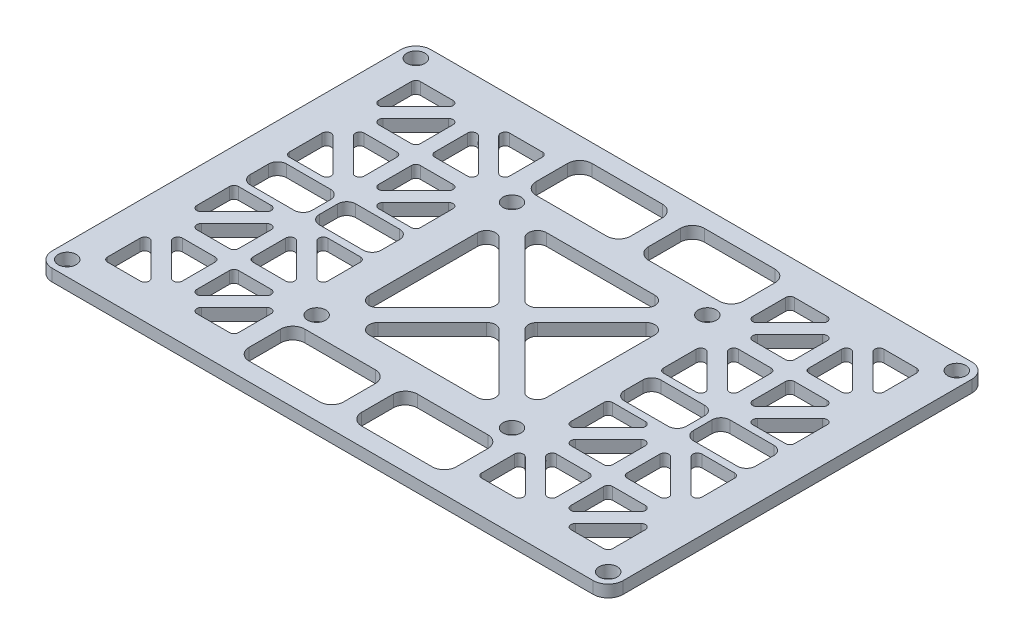
from build123d import *

# Parameters (mm, degrees)
SKETCH1_R           = 1.5
BOSS_EXTRUDE1_DEPTH = 2
SKETCH2_R           = 1.5
CUT_EXTRUDE1_DEPTH  = 3


with BuildPart() as part:
    # Sketch1 → Boss-Extrude1 (new body)
    with BuildSketch(Plane(origin=(0, 0, 0), x_dir=(1, 0, 0), z_dir=(0, 1, 0))):
        with BuildLine():
            Line((-45, -31.5), (45, -31.5))
            ThreePointArc((45, -31.5), (46.767766953, -30.767766953), (47.5, -29))
            Line((47.5, -29), (47.5, 29))
            ThreePointArc((47.5, 29), (46.767766953, 30.767766953), (45, 31.5))
            Line((45, 31.5), (-45, 31.5))
            ThreePointArc((-45, 31.5), (-46.767766953, 30.767766953), (-47.5, 29))
            Line((-47.5, 29), (-47.5, -29))
            ThreePointArc((-47.5, -29), (-46.767766953, -30.767766953), (-45, -31.5))
        make_face()
        with Locations((45, 29)):
            Circle(SKETCH1_R, mode=Mode.SUBTRACT)
        with Locations((45, -29)):
            Circle(SKETCH1_R, mode=Mode.SUBTRACT)
        with Locations((-45, 29)):
            Circle(SKETCH1_R, mode=Mode.SUBTRACT)
        with Locations((-45, -29)):
            Circle(SKETCH1_R, mode=Mode.SUBTRACT)
    extrude(amount=BOSS_EXTRUDE1_DEPTH)

    # Sketch2 → Cut-Extrude1 (cut, through all)
    with BuildSketch(Plane(origin=(0, 2, 0), x_dir=(1, 0, 0), z_dir=(0, 1, 0))):
        with Locations((-16.25, 16.25)):
            Circle(SKETCH2_R)
        with Locations((-16.25, -16.25)):
            Circle(SKETCH2_R)
        with Locations((16.25, 16.25)):
            Circle(SKETCH2_R)
        with Locations((16.25, -16.25)):
            Circle(SKETCH2_R)
        with BuildLine():
            Line((-12.189339828, 10.068019485), (-3.181980515, 1.060660172))
            ThreePointArc((-3.181980515, 1.060660172), (-2.742640687, 0), (-3.181980515, -1.060660172))
            Line((-3.181980515, -1.060660172), (-12.189339828, -10.068019485))
            ThreePointArc((-12.189339828, -10.068019485), (-13.824025149, -10.393178612), (-14.75, -9.007359313))
            Line((-14.75, -9.007359313), (-14.75, 9.007359313))
            ThreePointArc((-14.75, 9.007359313), (-13.824025149, 10.393178612), (-12.189339828, 10.068019485))
        make_face()
        with BuildLine():
            Line((1.060660172, 3.181980515), (10.068019485, 12.189339828))
            ThreePointArc((10.068019485, 12.189339828), (10.393178612, 13.824025149), (9.007359313, 14.75))
            Line((9.007359313, 14.75), (-9.007359313, 14.75))
            ThreePointArc((-9.007359313, 14.75), (-10.393178612, 13.824025149), (-10.068019485, 12.189339828))
            Line((-10.068019485, 12.189339828), (-1.060660172, 3.181980515))
            ThreePointArc((-1.060660172, 3.181980515), (0, 2.742640687), (1.060660172, 3.181980515))
        make_face()
        with BuildLine():
            Line((3.181980515, 1.060660172), (12.189339828, 10.068019485))
            ThreePointArc((12.189339828, 10.068019485), (13.824025149, 10.393178612), (14.75, 9.007359313))
            Line((14.75, 9.007359313), (14.75, -9.007359313))
            ThreePointArc((14.75, -9.007359313), (13.824025149, -10.393178612), (12.189339828, -10.068019485))
            Line((12.189339828, -10.068019485), (3.181980515, -1.060660172))
            ThreePointArc((3.181980515, -1.060660172), (2.742640687, 0), (3.181980515, 1.060660172))
        make_face()
        with BuildLine():
            Line((-9.007359313, -14.75), (9.007359313, -14.75))
            ThreePointArc((9.007359313, -14.75), (10.393178612, -13.824025149), (10.068019485, -12.189339828))
            Line((10.068019485, -12.189339828), (1.060660172, -3.181980515))
            ThreePointArc((1.060660172, -3.181980515), (0, -2.742640687), (-1.060660172, -3.181980515))
            Line((-1.060660172, -3.181980515), (-10.068019485, -12.189339828))
            ThreePointArc((-10.068019485, -12.189339828), (-10.393178612, -13.824025149), (-9.007359313, -14.75))
        make_face()
        with BuildLine():
            Line((35.832716447, 26.022056275), (41.272056275, 26.022056275))
            ThreePointArc((41.272056275, 26.022056275), (41.802386361, 25.802386361), (42.022056275, 25.272056275))
            Line((42.022056275, 25.272056275), (42.022056275, 19.832716447))
            ThreePointArc((42.022056275, 19.832716447), (41.559068849, 19.139806797), (40.741726189, 19.302386361))
            Line((40.741726189, 19.302386361), (35.302386361, 24.741726189))
            ThreePointArc((35.302386361, 24.741726189), (35.139806797, 25.559068849), (35.832716447, 26.022056275))
        make_face()
        with BuildLine():
            Line((33.605330086, 23.044669914), (39.044669914, 17.605330086))
            ThreePointArc((39.044669914, 17.605330086), (39.207249478, 16.787987426), (38.514339828, 16.325))
            Line((38.514339828, 16.325), (33.075, 16.325))
            ThreePointArc((33.075, 16.325), (32.544669914, 16.544669914), (32.325, 17.075))
            Line((32.325, 17.075), (32.325, 22.514339828))
            ThreePointArc((32.325, 22.514339828), (32.787987426, 23.207249478), (33.605330086, 23.044669914))
        make_face()
        with BuildLine():
            Line((33.075, 13.925), (38.514339828, 13.925))
            ThreePointArc((38.514339828, 13.925), (39.207249478, 13.462012574), (39.044669914, 12.644669914))
            Line((39.044669914, 12.644669914), (33.605330086, 7.205330086))
            ThreePointArc((33.605330086, 7.205330086), (32.787987426, 7.042750522), (32.325, 7.735660172))
            Line((32.325, 7.735660172), (32.325, 13.175))
            ThreePointArc((32.325, 13.175), (32.544669914, 13.705330086), (33.075, 13.925))
        make_face()
        with BuildLine():
            Line((35.302386361, 5.508273811), (40.741726189, 10.947613639))
            ThreePointArc((40.741726189, 10.947613639), (41.559068849, 11.110193203), (42.022056275, 10.417283553))
            Line((42.022056275, 10.417283553), (42.022056275, 4.977943725))
            ThreePointArc((42.022056275, 4.977943725), (41.802386361, 4.447613639), (41.272056275, 4.227943725))
            Line((41.272056275, 4.227943725), (35.832716447, 4.227943725))
            ThreePointArc((35.832716447, 4.227943725), (35.139806797, 4.690931151), (35.302386361, 5.508273811))
        make_face()
        with BuildLine():
            Line((29.925, 13.175), (29.925, 7.735660172))
            ThreePointArc((29.925, 7.735660172), (29.462012574, 7.042750522), (28.644669914, 7.205330086))
            Line((28.644669914, 7.205330086), (23.205330086, 12.644669914))
            ThreePointArc((23.205330086, 12.644669914), (23.042750522, 13.462012574), (23.735660172, 13.925))
            Line((23.735660172, 13.925), (29.175, 13.925))
            ThreePointArc((29.175, 13.925), (29.705330086, 13.705330086), (29.925, 13.175))
        make_face()
        with BuildLine():
            Line((21.508273811, 10.947613639), (26.947613639, 5.508273811))
            ThreePointArc((26.947613639, 5.508273811), (27.110193203, 4.690931151), (26.417283553, 4.227943725))
            Line((26.417283553, 4.227943725), (20.977943725, 4.227943725))
            ThreePointArc((20.977943725, 4.227943725), (20.447613639, 4.447613639), (20.227943725, 4.977943725))
            Line((20.227943725, 4.977943725), (20.227943725, 10.417283553))
            ThreePointArc((20.227943725, 10.417283553), (20.690931151, 11.110193203), (21.508273811, 10.947613639))
        make_face()
        with BuildLine():
            Line((29.175, 16.325), (23.735660172, 16.325))
            ThreePointArc((23.735660172, 16.325), (23.042750522, 16.787987426), (23.205330086, 17.605330086))
            Line((23.205330086, 17.605330086), (28.644669914, 23.044669914))
            ThreePointArc((28.644669914, 23.044669914), (29.462012574, 23.207249478), (29.925, 22.514339828))
            Line((29.925, 22.514339828), (29.925, 17.075))
            ThreePointArc((29.925, 17.075), (29.705330086, 16.544669914), (29.175, 16.325))
        make_face()
        with BuildLine():
            Line((26.947613639, 24.741726189), (21.508273811, 19.302386361))
            ThreePointArc((21.508273811, 19.302386361), (20.690931151, 19.139806797), (20.227943725, 19.832716447))
            Line((20.227943725, 19.832716447), (20.227943725, 25.272056275))
            ThreePointArc((20.227943725, 25.272056275), (20.447613639, 25.802386361), (20.977943725, 26.022056275))
            Line((20.977943725, 26.022056275), (26.417283553, 26.022056275))
            ThreePointArc((26.417283553, 26.022056275), (27.110193203, 25.559068849), (26.947613639, 24.741726189))
        make_face()
        with BuildLine():
            Line((33.075, -16.325), (38.514339828, -16.325))
            ThreePointArc((38.514339828, -16.325), (39.207249478, -16.787987426), (39.044669914, -17.605330086))
            Line((39.044669914, -17.605330086), (33.605330086, -23.044669914))
            ThreePointArc((33.605330086, -23.044669914), (32.787987426, -23.207249478), (32.325, -22.514339828))
            Line((32.325, -22.514339828), (32.325, -17.075))
            ThreePointArc((32.325, -17.075), (32.544669914, -16.544669914), (33.075, -16.325))
        make_face()
        with BuildLine():
            Line((35.302386361, -24.741726189), (40.741726189, -19.302386361))
            ThreePointArc((40.741726189, -19.302386361), (41.559068849, -19.139806797), (42.022056275, -19.832716447))
            Line((42.022056275, -19.832716447), (42.022056275, -25.272056275))
            ThreePointArc((42.022056275, -25.272056275), (41.802386361, -25.802386361), (41.272056275, -26.022056275))
            Line((41.272056275, -26.022056275), (35.832716447, -26.022056275))
            ThreePointArc((35.832716447, -26.022056275), (35.139806797, -25.559068849), (35.302386361, -24.741726189))
        make_face()
        with BuildLine():
            Line((29.925, -17.075), (29.925, -22.514339828))
            ThreePointArc((29.925, -22.514339828), (29.462012574, -23.207249478), (28.644669914, -23.044669914))
            Line((28.644669914, -23.044669914), (23.205330086, -17.605330086))
            ThreePointArc((23.205330086, -17.605330086), (23.042750522, -16.787987426), (23.735660172, -16.325))
            Line((23.735660172, -16.325), (29.175, -16.325))
            ThreePointArc((29.175, -16.325), (29.705330086, -16.544669914), (29.925, -17.075))
        make_face()
        with BuildLine():
            Line((21.508273811, -19.302386361), (26.947613639, -24.741726189))
            ThreePointArc((26.947613639, -24.741726189), (27.110193203, -25.559068849), (26.417283553, -26.022056275))
            Line((26.417283553, -26.022056275), (20.977943725, -26.022056275))
            ThreePointArc((20.977943725, -26.022056275), (20.447613639, -25.802386361), (20.227943725, -25.272056275))
            Line((20.227943725, -25.272056275), (20.227943725, -19.832716447))
            ThreePointArc((20.227943725, -19.832716447), (20.690931151, -19.139806797), (21.508273811, -19.302386361))
        make_face()
        with BuildLine():
            Line((29.175, -13.925), (23.735660172, -13.925))
            ThreePointArc((23.735660172, -13.925), (23.042750522, -13.462012574), (23.205330086, -12.644669914))
            Line((23.205330086, -12.644669914), (28.644669914, -7.205330086))
            ThreePointArc((28.644669914, -7.205330086), (29.462012574, -7.042750522), (29.925, -7.735660172))
            Line((29.925, -7.735660172), (29.925, -13.175))
            ThreePointArc((29.925, -13.175), (29.705330086, -13.705330086), (29.175, -13.925))
        make_face()
        with BuildLine():
            Line((26.947613639, -5.508273811), (21.508273811, -10.947613639))
            ThreePointArc((21.508273811, -10.947613639), (20.690931151, -11.110193203), (20.227943725, -10.417283553))
            Line((20.227943725, -10.417283553), (20.227943725, -4.977943725))
            ThreePointArc((20.227943725, -4.977943725), (20.447613639, -4.447613639), (20.977943725, -4.227943725))
            Line((20.977943725, -4.227943725), (26.417283553, -4.227943725))
            ThreePointArc((26.417283553, -4.227943725), (27.110193203, -4.690931151), (26.947613639, -5.508273811))
        make_face()
        with BuildLine():
            Line((32.325, -13.175), (32.325, -7.735660172))
            ThreePointArc((32.325, -7.735660172), (32.787987426, -7.042750522), (33.605330086, -7.205330086))
            Line((33.605330086, -7.205330086), (39.044669914, -12.644669914))
            ThreePointArc((39.044669914, -12.644669914), (39.207249478, -13.462012574), (38.514339828, -13.925))
            Line((38.514339828, -13.925), (33.075, -13.925))
            ThreePointArc((33.075, -13.925), (32.544669914, -13.705330086), (32.325, -13.175))
        make_face()
        with BuildLine():
            Line((40.741726189, -10.947613639), (35.302386361, -5.508273811))
            ThreePointArc((35.302386361, -5.508273811), (35.139806797, -4.690931151), (35.832716447, -4.227943725))
            Line((35.832716447, -4.227943725), (41.272056275, -4.227943725))
            ThreePointArc((41.272056275, -4.227943725), (41.802386361, -4.447613639), (42.022056275, -4.977943725))
            Line((42.022056275, -4.977943725), (42.022056275, -10.417283553))
            ThreePointArc((42.022056275, -10.417283553), (41.559068849, -11.110193203), (40.741726189, -10.947613639))
        make_face()
        with BuildLine():
            Line((21.727943725, -3.027943725), (29.025, -3.027943725))
            ThreePointArc((29.025, -3.027943725), (30.085660172, -2.588603897), (30.525, -1.527943725))
            Line((30.525, -1.527943725), (30.525, 1.527943725))
            ThreePointArc((30.525, 1.527943725), (30.085660172, 2.588603897), (29.025, 3.027943725))
            Line((29.025, 3.027943725), (21.727943725, 3.027943725))
            ThreePointArc((21.727943725, 3.027943725), (20.667283553, 2.588603897), (20.227943725, 1.527943725))
            Line((20.227943725, 1.527943725), (20.227943725, -1.527943725))
            ThreePointArc((20.227943725, -1.527943725), (20.667283553, -2.588603897), (21.727943725, -3.027943725))
        make_face()
        with BuildLine():
            Line((42.022056275, -1.527943725), (42.022056275, 1.527943725))
            ThreePointArc((42.022056275, 1.527943725), (41.582716447, 2.588603897), (40.522056275, 3.027943725))
            Line((40.522056275, 3.027943725), (33.225, 3.027943725))
            ThreePointArc((33.225, 3.027943725), (32.164339828, 2.588603897), (31.725, 1.527943725))
            Line((31.725, 1.527943725), (31.725, -1.527943725))
            ThreePointArc((31.725, -1.527943725), (32.164339828, -2.588603897), (33.225, -3.027943725))
            Line((33.225, -3.027943725), (40.522056275, -3.027943725))
            ThreePointArc((40.522056275, -3.027943725), (41.582716447, -2.588603897), (42.022056275, -1.527943725))
        make_face()
        with BuildLine():
            Line((-20.227943725, -25.272056275), (-20.227943725, -19.832716447))
            ThreePointArc((-20.227943725, -19.832716447), (-20.690931151, -19.139806797), (-21.508273811, -19.302386361))
            Line((-21.508273811, -19.302386361), (-26.947613639, -24.741726189))
            ThreePointArc((-26.947613639, -24.741726189), (-27.110193203, -25.559068849), (-26.417283553, -26.022056275))
            Line((-26.417283553, -26.022056275), (-20.977943725, -26.022056275))
            ThreePointArc((-20.977943725, -26.022056275), (-20.447613639, -25.802386361), (-20.227943725, -25.272056275))
        make_face()
        with BuildLine():
            Line((-41.272056275, -26.022056275), (-35.832716447, -26.022056275))
            ThreePointArc((-35.832716447, -26.022056275), (-35.139806797, -25.559068849), (-35.302386361, -24.741726189))
            Line((-35.302386361, -24.741726189), (-40.741726189, -19.302386361))
            ThreePointArc((-40.741726189, -19.302386361), (-41.559068849, -19.139806797), (-42.022056275, -19.832716447))
            Line((-42.022056275, -19.832716447), (-42.022056275, -25.272056275))
            ThreePointArc((-42.022056275, -25.272056275), (-41.802386361, -25.802386361), (-41.272056275, -26.022056275))
        make_face()
        with BuildLine():
            Line((-32.325, -22.514339828), (-32.325, -17.075))
            ThreePointArc((-32.325, -17.075), (-32.544669914, -16.544669914), (-33.075, -16.325))
            Line((-33.075, -16.325), (-38.514339828, -16.325))
            ThreePointArc((-38.514339828, -16.325), (-39.207249478, -16.787987426), (-39.044669914, -17.605330086))
            Line((-39.044669914, -17.605330086), (-33.605330086, -23.044669914))
            ThreePointArc((-33.605330086, -23.044669914), (-32.787987426, -23.207249478), (-32.325, -22.514339828))
        make_face()
        with BuildLine():
            Line((-23.735660172, -16.325), (-29.175, -16.325))
            ThreePointArc((-29.175, -16.325), (-29.705330086, -16.544669914), (-29.925, -17.075))
            Line((-29.925, -17.075), (-29.925, -22.514339828))
            ThreePointArc((-29.925, -22.514339828), (-29.462012574, -23.207249478), (-28.644669914, -23.044669914))
            Line((-28.644669914, -23.044669914), (-23.205330086, -17.605330086))
            ThreePointArc((-23.205330086, -17.605330086), (-23.042750522, -16.787987426), (-23.735660172, -16.325))
        make_face()
        with BuildLine():
            Line((-20.977943725, -4.227943725), (-26.417283553, -4.227943725))
            ThreePointArc((-26.417283553, -4.227943725), (-27.110193203, -4.690931151), (-26.947613639, -5.508273811))
            Line((-26.947613639, -5.508273811), (-21.508273811, -10.947613639))
            ThreePointArc((-21.508273811, -10.947613639), (-20.690931151, -11.110193203), (-20.227943725, -10.417283553))
            Line((-20.227943725, -10.417283553), (-20.227943725, -4.977943725))
            ThreePointArc((-20.227943725, -4.977943725), (-20.447613639, -4.447613639), (-20.977943725, -4.227943725))
        make_face()
        with BuildLine():
            Line((-29.925, -7.735660172), (-29.925, -13.175))
            ThreePointArc((-29.925, -13.175), (-29.705330086, -13.705330086), (-29.175, -13.925))
            Line((-29.175, -13.925), (-23.735660172, -13.925))
            ThreePointArc((-23.735660172, -13.925), (-23.042750522, -13.462012574), (-23.205330086, -12.644669914))
            Line((-23.205330086, -12.644669914), (-28.644669914, -7.205330086))
            ThreePointArc((-28.644669914, -7.205330086), (-29.462012574, -7.042750522), (-29.925, -7.735660172))
        make_face()
        with BuildLine():
            Line((-38.514339828, -13.925), (-33.075, -13.925))
            ThreePointArc((-33.075, -13.925), (-32.544669914, -13.705330086), (-32.325, -13.175))
            Line((-32.325, -13.175), (-32.325, -7.735660172))
            ThreePointArc((-32.325, -7.735660172), (-32.787987426, -7.042750522), (-33.605330086, -7.205330086))
            Line((-33.605330086, -7.205330086), (-39.044669914, -12.644669914))
            ThreePointArc((-39.044669914, -12.644669914), (-39.207249478, -13.462012574), (-38.514339828, -13.925))
        make_face()
        with BuildLine():
            Line((-42.022056275, -4.977943725), (-42.022056275, -10.417283553))
            ThreePointArc((-42.022056275, -10.417283553), (-41.559068849, -11.110193203), (-40.741726189, -10.947613639))
            Line((-40.741726189, -10.947613639), (-35.302386361, -5.508273811))
            ThreePointArc((-35.302386361, -5.508273811), (-35.139806797, -4.690931151), (-35.832716447, -4.227943725))
            Line((-35.832716447, -4.227943725), (-41.272056275, -4.227943725))
            ThreePointArc((-41.272056275, -4.227943725), (-41.802386361, -4.447613639), (-42.022056275, -4.977943725))
        make_face()
        with BuildLine():
            Line((-33.225, -3.027943725), (-40.522056275, -3.027943725))
            ThreePointArc((-40.522056275, -3.027943725), (-41.582716447, -2.588603897), (-42.022056275, -1.527943725))
            Line((-42.022056275, -1.527943725), (-42.022056275, 1.527943725))
            ThreePointArc((-42.022056275, 1.527943725), (-41.582716447, 2.588603897), (-40.522056275, 3.027943725))
            Line((-40.522056275, 3.027943725), (-33.225, 3.027943725))
            ThreePointArc((-33.225, 3.027943725), (-32.164339828, 2.588603897), (-31.725, 1.527943725))
            Line((-31.725, 1.527943725), (-31.725, -1.527943725))
            ThreePointArc((-31.725, -1.527943725), (-32.164339828, -2.588603897), (-33.225, -3.027943725))
        make_face()
        with BuildLine():
            Line((-20.227943725, -1.527943725), (-20.227943725, 1.527943725))
            ThreePointArc((-20.227943725, 1.527943725), (-20.667283553, 2.588603897), (-21.727943725, 3.027943725))
            Line((-21.727943725, 3.027943725), (-29.025, 3.027943725))
            ThreePointArc((-29.025, 3.027943725), (-30.085660172, 2.588603897), (-30.525, 1.527943725))
            Line((-30.525, 1.527943725), (-30.525, -1.527943725))
            ThreePointArc((-30.525, -1.527943725), (-30.085660172, -2.588603897), (-29.025, -3.027943725))
            Line((-29.025, -3.027943725), (-21.727943725, -3.027943725))
            ThreePointArc((-21.727943725, -3.027943725), (-20.667283553, -2.588603897), (-20.227943725, -1.527943725))
        make_face()
        with BuildLine():
            Line((-20.227943725, 4.977943725), (-20.227943725, 10.417283553))
            ThreePointArc((-20.227943725, 10.417283553), (-20.690931151, 11.110193203), (-21.508273811, 10.947613639))
            Line((-21.508273811, 10.947613639), (-26.947613639, 5.508273811))
            ThreePointArc((-26.947613639, 5.508273811), (-27.110193203, 4.690931151), (-26.417283553, 4.227943725))
            Line((-26.417283553, 4.227943725), (-20.977943725, 4.227943725))
            ThreePointArc((-20.977943725, 4.227943725), (-20.447613639, 4.447613639), (-20.227943725, 4.977943725))
        make_face()
        with BuildLine():
            Line((-41.272056275, 4.227943725), (-35.832716447, 4.227943725))
            ThreePointArc((-35.832716447, 4.227943725), (-35.139806797, 4.690931151), (-35.302386361, 5.508273811))
            Line((-35.302386361, 5.508273811), (-40.741726189, 10.947613639))
            ThreePointArc((-40.741726189, 10.947613639), (-41.559068849, 11.110193203), (-42.022056275, 10.417283553))
            Line((-42.022056275, 10.417283553), (-42.022056275, 4.977943725))
            ThreePointArc((-42.022056275, 4.977943725), (-41.802386361, 4.447613639), (-41.272056275, 4.227943725))
        make_face()
        with BuildLine():
            Line((-23.735660172, 13.925), (-29.175, 13.925))
            ThreePointArc((-29.175, 13.925), (-29.705330086, 13.705330086), (-29.925, 13.175))
            Line((-29.925, 13.175), (-29.925, 7.735660172))
            ThreePointArc((-29.925, 7.735660172), (-29.462012574, 7.042750522), (-28.644669914, 7.205330086))
            Line((-28.644669914, 7.205330086), (-23.205330086, 12.644669914))
            ThreePointArc((-23.205330086, 12.644669914), (-23.042750522, 13.462012574), (-23.735660172, 13.925))
        make_face()
        with BuildLine():
            Line((-32.325, 7.735660172), (-32.325, 13.175))
            ThreePointArc((-32.325, 13.175), (-32.544669914, 13.705330086), (-33.075, 13.925))
            Line((-33.075, 13.925), (-38.514339828, 13.925))
            ThreePointArc((-38.514339828, 13.925), (-39.207249478, 13.462012574), (-39.044669914, 12.644669914))
            Line((-39.044669914, 12.644669914), (-33.605330086, 7.205330086))
            ThreePointArc((-33.605330086, 7.205330086), (-32.787987426, 7.042750522), (-32.325, 7.735660172))
        make_face()
        with BuildLine():
            Line((-42.022056275, 25.272056275), (-42.022056275, 19.832716447))
            ThreePointArc((-42.022056275, 19.832716447), (-41.559068849, 19.139806797), (-40.741726189, 19.302386361))
            Line((-40.741726189, 19.302386361), (-35.302386361, 24.741726189))
            ThreePointArc((-35.302386361, 24.741726189), (-35.139806797, 25.559068849), (-35.832716447, 26.022056275))
            Line((-35.832716447, 26.022056275), (-41.272056275, 26.022056275))
            ThreePointArc((-41.272056275, 26.022056275), (-41.802386361, 25.802386361), (-42.022056275, 25.272056275))
        make_face()
        with BuildLine():
            Line((-38.514339828, 16.325), (-33.075, 16.325))
            ThreePointArc((-33.075, 16.325), (-32.544669914, 16.544669914), (-32.325, 17.075))
            Line((-32.325, 17.075), (-32.325, 22.514339828))
            ThreePointArc((-32.325, 22.514339828), (-32.787987426, 23.207249478), (-33.605330086, 23.044669914))
            Line((-33.605330086, 23.044669914), (-39.044669914, 17.605330086))
            ThreePointArc((-39.044669914, 17.605330086), (-39.207249478, 16.787987426), (-38.514339828, 16.325))
        make_face()
        with BuildLine():
            Line((-29.925, 22.514339828), (-29.925, 17.075))
            ThreePointArc((-29.925, 17.075), (-29.705330086, 16.544669914), (-29.175, 16.325))
            Line((-29.175, 16.325), (-23.735660172, 16.325))
            ThreePointArc((-23.735660172, 16.325), (-23.042750522, 16.787987426), (-23.205330086, 17.605330086))
            Line((-23.205330086, 17.605330086), (-28.644669914, 23.044669914))
            ThreePointArc((-28.644669914, 23.044669914), (-29.462012574, 23.207249478), (-29.925, 22.514339828))
        make_face()
        with BuildLine():
            Line((-20.977943725, 26.022056275), (-26.417283553, 26.022056275))
            ThreePointArc((-26.417283553, 26.022056275), (-27.110193203, 25.559068849), (-26.947613639, 24.741726189))
            Line((-26.947613639, 24.741726189), (-21.508273811, 19.302386361))
            ThreePointArc((-21.508273811, 19.302386361), (-20.690931151, 19.139806797), (-20.227943725, 19.832716447))
            Line((-20.227943725, 19.832716447), (-20.227943725, 25.272056275))
            ThreePointArc((-20.227943725, 25.272056275), (-20.447613639, 25.802386361), (-20.977943725, 26.022056275))
        make_face()
        with BuildLine():
            Line((-15.227943725, -28.5), (-3.5, -28.5))
            ThreePointArc((-3.5, -28.5), (-2.085786438, -27.914213562), (-1.5, -26.5))
            Line((-1.5, -26.5), (-1.5, -21.25))
            ThreePointArc((-1.5, -21.25), (-2.085786438, -19.835786438), (-3.5, -19.25))
            Line((-3.5, -19.25), (-15.227943725, -19.25))
            ThreePointArc((-15.227943725, -19.25), (-16.642157288, -19.835786438), (-17.227943725, -21.25))
            Line((-17.227943725, -21.25), (-17.227943725, -26.5))
            ThreePointArc((-17.227943725, -26.5), (-16.642157288, -27.914213562), (-15.227943725, -28.5))
        make_face()
        with BuildLine():
            Line((17.227943725, -26.5), (17.227943725, -21.25))
            ThreePointArc((17.227943725, -21.25), (16.642157288, -19.835786438), (15.227943725, -19.25))
            Line((15.227943725, -19.25), (3.5, -19.25))
            ThreePointArc((3.5, -19.25), (2.085786438, -19.835786438), (1.5, -21.25))
            Line((1.5, -21.25), (1.5, -26.5))
            ThreePointArc((1.5, -26.5), (2.085786438, -27.914213562), (3.5, -28.5))
            Line((3.5, -28.5), (15.227943725, -28.5))
            ThreePointArc((15.227943725, -28.5), (16.642157288, -27.914213562), (17.227943725, -26.5))
        make_face()
        with BuildLine():
            Line((3.5, 28.5), (15.227943725, 28.5))
            ThreePointArc((15.227943725, 28.5), (16.642157288, 27.914213562), (17.227943725, 26.5))
            Line((17.227943725, 26.5), (17.227943725, 21.25))
            ThreePointArc((17.227943725, 21.25), (16.642157288, 19.835786438), (15.227943725, 19.25))
            Line((15.227943725, 19.25), (3.5, 19.25))
            ThreePointArc((3.5, 19.25), (2.085786438, 19.835786438), (1.5, 21.25))
            Line((1.5, 21.25), (1.5, 26.5))
            ThreePointArc((1.5, 26.5), (2.085786438, 27.914213562), (3.5, 28.5))
        make_face()
        with BuildLine():
            Line((-17.227943725, 26.5), (-17.227943725, 21.25))
            ThreePointArc((-17.227943725, 21.25), (-16.642157288, 19.835786438), (-15.227943725, 19.25))
            Line((-15.227943725, 19.25), (-3.5, 19.25))
            ThreePointArc((-3.5, 19.25), (-2.085786438, 19.835786438), (-1.5, 21.25))
            Line((-1.5, 21.25), (-1.5, 26.5))
            ThreePointArc((-1.5, 26.5), (-2.085786438, 27.914213562), (-3.5, 28.5))
            Line((-3.5, 28.5), (-15.227943725, 28.5))
            ThreePointArc((-15.227943725, 28.5), (-16.642157288, 27.914213562), (-17.227943725, 26.5))
        make_face()
    extrude(amount=-CUT_EXTRUDE1_DEPTH, mode=Mode.SUBTRACT)


solid = part.part
